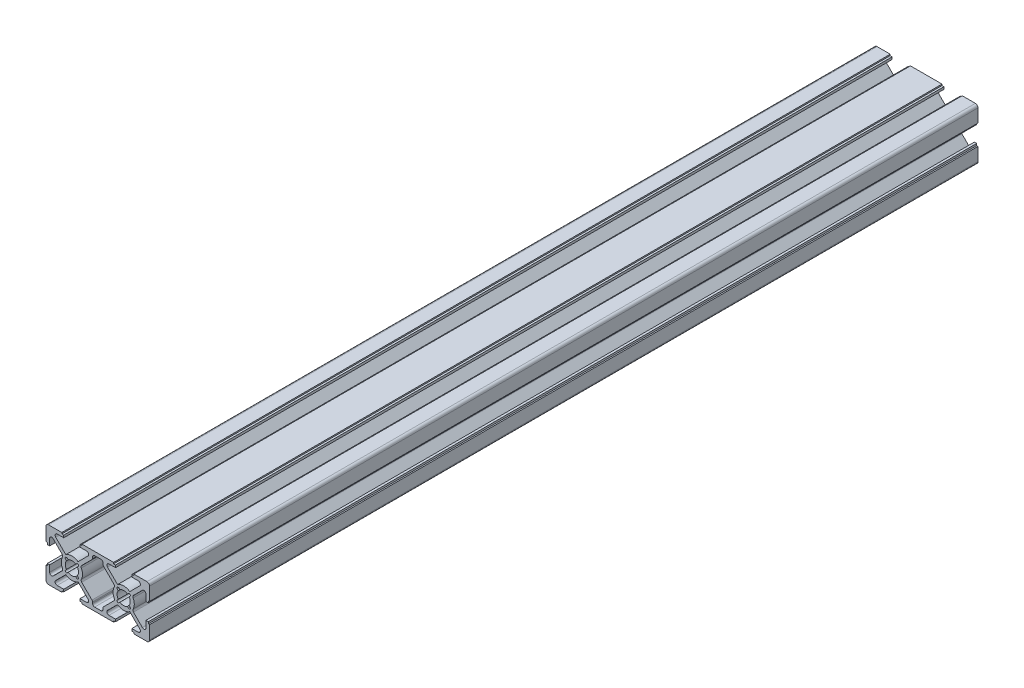
from build123d import *

# Parameters (mm, degrees)
Y_KSEKLIK_EKSTR_ZYON2_DEPTH = 160
RADYUS1_R                   = 0.8


with BuildPart() as part:
    # Çizim3 → Yükseklik-Ekstrüzyon2 (new body, symmetric)
    with BuildSketch(Plane.XY):
        with BuildLine():
            Line((1, 0), (6.1, 0))
            Line((6.1, 0), (6.1, 0.5))
            Line((6.1, 0.5), (6.85, 0.5))
            Line((6.85, 0.5), (6.85, 1.4))
            Line((6.85, 1.4), (4.321320344, 1.4))
            ThreePointArc((4.321320344, 1.4), (3.582216718, 1.893853254), (3.755634919, 2.765685425))
            Line((3.755634919, 2.765685425), (7.638403375, 6.648453882))
            ThreePointArc((7.638403375, 6.648453882), (10, 5.9), (12.361596625, 6.648453882))
            Line((12.361596625, 6.648453882), (16.244365081, 2.765685425))
            ThreePointArc((16.244365081, 2.765685425), (16.417783282, 1.893853254), (15.678679656, 1.4))
            Line((15.678679656, 1.4), (13.15, 1.4))
            Line((13.15, 1.4), (13.15, 0.5))
            Line((13.15, 0.5), (13.9, 0.5))
            Line((13.9, 0.5), (13.9, 0))
            Line((13.9, 0), (26.1, 0))
            Line((26.1, 0), (26.1, 0.5))
            Line((26.1, 0.5), (26.85, 0.5))
            Line((26.85, 0.5), (26.85, 1.4))
            Line((26.85, 1.4), (24.321320344, 1.4))
            ThreePointArc((24.321320344, 1.4), (23.582216718, 1.893853254), (23.755634919, 2.765685425))
            Line((23.755634919, 2.765685425), (27.638403375, 6.648453882))
            ThreePointArc((27.638403375, 6.648453882), (30, 5.9), (32.361596625, 6.648453882))
            Line((32.361596625, 6.648453882), (36.244365081, 2.765685425))
            ThreePointArc((36.244365081, 2.765685425), (36.417783282, 1.893853254), (35.678679656, 1.4))
            Line((35.678679656, 1.4), (33.15, 1.4))
            Line((33.15, 1.4), (33.15, 0.5))
            Line((33.15, 0.5), (33.9, 0.5))
            Line((33.9, 0.5), (33.9, 0))
            Line((33.9, 0), (39, 0))
            ThreePointArc((39, 0), (39.707106781, 0.292893219), (40, 1))
            Line((40, 1), (40, 6.1))
            Line((40, 6.1), (39.5, 6.1))
            Line((39.5, 6.1), (39.5, 6.85))
            Line((39.5, 6.85), (38.6, 6.85))
            Line((38.6, 6.85), (38.6, 4.321320344))
            ThreePointArc((38.6, 4.321320344), (38.106146746, 3.582216718), (37.234314575, 3.755634919))
            Line((37.234314575, 3.755634919), (33.351546118, 7.638403375))
            ThreePointArc((33.351546118, 7.638403375), (34.1, 10), (33.351546118, 12.361596625))
            Line((33.351546118, 12.361596625), (37.234314575, 16.244365081))
            ThreePointArc((37.234314575, 16.244365081), (38.106146746, 16.417783282), (38.6, 15.678679656))
            Line((38.6, 15.678679656), (38.6, 13.15))
            Line((38.6, 13.15), (39.5, 13.15))
            Line((39.5, 13.15), (39.5, 13.9))
            Line((39.5, 13.9), (40, 13.9))
            Line((40, 13.9), (40, 19))
            ThreePointArc((40, 19), (39.707106781, 19.707106781), (39, 20))
            Line((39, 20), (33.9, 20))
            Line((33.9, 20), (33.9, 19.5))
            Line((33.9, 19.5), (33.15, 19.5))
            Line((33.15, 19.5), (33.15, 18.6))
            Line((33.15, 18.6), (35.678679656, 18.6))
            ThreePointArc((35.678679656, 18.6), (36.417783282, 18.106146746), (36.244365081, 17.234314575))
            Line((36.244365081, 17.234314575), (32.361596625, 13.351546118))
            ThreePointArc((32.361596625, 13.351546118), (30, 14.1), (27.638403375, 13.351546118))
            Line((27.638403375, 13.351546118), (23.755634919, 17.234314575))
            ThreePointArc((23.755634919, 17.234314575), (23.582216718, 18.106146746), (24.321320344, 18.6))
            Line((24.321320344, 18.6), (26.85, 18.6))
            Line((26.85, 18.6), (26.85, 19.5))
            Line((26.85, 19.5), (26.1, 19.5))
            Line((26.1, 19.5), (26.1, 20))
            Line((26.1, 20), (13.9, 20))
            Line((13.9, 20), (13.9, 19.5))
            Line((13.9, 19.5), (13.15, 19.5))
            Line((13.15, 19.5), (13.15, 18.6))
            Line((13.15, 18.6), (15.678679656, 18.6))
            ThreePointArc((15.678679656, 18.6), (16.417783282, 18.106146746), (16.244365081, 17.234314575))
            Line((16.244365081, 17.234314575), (12.361596625, 13.351546118))
            ThreePointArc((12.361596625, 13.351546118), (10, 14.1), (7.638403375, 13.351546118))
            Line((7.638403375, 13.351546118), (3.755634919, 17.234314575))
            ThreePointArc((3.755634919, 17.234314575), (3.582216718, 18.106146746), (4.321320344, 18.6))
            Line((4.321320344, 18.6), (6.85, 18.6))
            Line((6.85, 18.6), (6.85, 19.5))
            Line((6.85, 19.5), (6.1, 19.5))
            Line((6.1, 19.5), (6.1, 20))
            Line((6.1, 20), (1, 20))
            ThreePointArc((1, 20), (0.292893219, 19.707106781), (0, 19))
            Line((0, 19), (0, 13.9))
            Line((0, 13.9), (0.5, 13.9))
            Line((0.5, 13.9), (0.5, 13.15))
            Line((0.5, 13.15), (1.4, 13.15))
            Line((1.4, 13.15), (1.4, 15.678679656))
            ThreePointArc((1.4, 15.678679656), (1.893853254, 16.417783282), (2.765685425, 16.244365081))
            Line((2.765685425, 16.244365081), (6.648453882, 12.361596625))
            ThreePointArc((6.648453882, 12.361596625), (5.9, 10), (6.648453882, 7.638403375))
            Line((6.648453882, 7.638403375), (2.765685425, 3.755634919))
            ThreePointArc((2.765685425, 3.755634919), (1.893853254, 3.582216718), (1.4, 4.321320344))
            Line((1.4, 4.321320344), (1.4, 6.85))
            Line((1.4, 6.85), (0.5, 6.85))
            Line((0.5, 6.85), (0.5, 6.1))
            Line((0.5, 6.1), (0, 6.1))
            Line((0, 6.1), (0, 1))
            ThreePointArc((0, 1), (0.292893219, 0.292893219), (1, 0))
        make_face()
        with BuildLine():
            Line((21.210320913, 18.6), (18.789679087, 18.6))
            ThreePointArc((18.789679087, 18.6), (18.223993662, 18.365685425), (17.989679087, 17.8))
            Line((17.989679087, 17.8), (17.989679087, 17.331100443))
            ThreePointArc((17.989679087, 17.331100443), (17.928782713, 17.024953697), (17.755364512, 16.765415018))
            Line((17.755364512, 16.765415018), (13.351546118, 12.361596625))
            ThreePointArc((13.351546118, 12.361596625), (14.1, 10), (13.351546118, 7.638403375))
            Line((13.351546118, 7.638403375), (17.755364512, 3.234584982))
            ThreePointArc((17.755364512, 3.234584982), (17.928782713, 2.975046303), (17.989679087, 2.668899557))
            Line((17.989679087, 2.668899557), (17.989679087, 2.2))
            ThreePointArc((17.989679087, 2.2), (18.223993662, 1.634314575), (18.789679087, 1.4))
            Line((18.789679087, 1.4), (21.210320913, 1.4))
            ThreePointArc((21.210320913, 1.4), (21.776006338, 1.634314575), (22.010320913, 2.2))
            Line((22.010320913, 2.2), (22.010320913, 2.668899557))
            ThreePointArc((22.010320913, 2.668899557), (22.071217287, 2.975046303), (22.244635488, 3.234584982))
            Line((22.244635488, 3.234584982), (26.648453882, 7.638403375))
            ThreePointArc((26.648453882, 7.638403375), (25.9, 10), (26.648453882, 12.361596625))
            Line((26.648453882, 12.361596625), (22.244635488, 16.765415018))
            ThreePointArc((22.244635488, 16.765415018), (22.071217287, 17.024953697), (22.010320913, 17.331100443))
            Line((22.010320913, 17.331100443), (22.010320913, 17.8))
            ThreePointArc((22.010320913, 17.8), (21.776006338, 18.365685425), (21.210320913, 18.6))
        make_face(mode=Mode.SUBTRACT)
        with BuildLine():
            Line((8.201142588, 12.443783276), (8.552743846, 12.092182018))
            ThreePointArc((8.552743846, 12.092182018), (10, 12.543968548), (11.447256154, 12.092182018))
            Line((11.447256154, 12.092182018), (11.798857412, 12.443783276))
            ThreePointArc((11.798857412, 12.443783276), (12.443783276, 12.443783276), (12.443783276, 11.798857412))
            Line((12.443783276, 11.798857412), (12.092182018, 11.447256154))
            ThreePointArc((12.092182018, 11.447256154), (12.543968548, 10), (12.092182018, 8.552743846))
            Line((12.092182018, 8.552743846), (12.443783276, 8.201142588))
            ThreePointArc((12.443783276, 8.201142588), (12.443783276, 7.556216724), (11.798857412, 7.556216724))
            Line((11.798857412, 7.556216724), (11.447256154, 7.907817982))
            ThreePointArc((11.447256154, 7.907817982), (10, 7.456031452), (8.552743846, 7.907817982))
            Line((8.552743846, 7.907817982), (8.201142588, 7.556216724))
            ThreePointArc((8.201142588, 7.556216724), (7.556216724, 7.556216724), (7.556216724, 8.201142588))
            Line((7.556216724, 8.201142588), (7.907817982, 8.552743846))
            ThreePointArc((7.907817982, 8.552743846), (7.456031452, 10), (7.907817982, 11.447256154))
            Line((7.907817982, 11.447256154), (7.556216724, 11.798857412))
            ThreePointArc((7.556216724, 11.798857412), (7.556216724, 12.443783276), (8.201142588, 12.443783276))
        make_face(mode=Mode.SUBTRACT)
        with BuildLine():
            Line((27.907817982, 11.447256154), (27.556216724, 11.798857412))
            ThreePointArc((27.556216724, 11.798857412), (27.556216724, 12.443783276), (28.201142588, 12.443783276))
            Line((28.201142588, 12.443783276), (28.552743846, 12.092182018))
            ThreePointArc((28.552743846, 12.092182018), (30, 12.543968548), (31.447256154, 12.092182018))
            Line((31.447256154, 12.092182018), (31.798857412, 12.443783276))
            ThreePointArc((31.798857412, 12.443783276), (32.443783276, 12.443783276), (32.443783276, 11.798857412))
            Line((32.443783276, 11.798857412), (32.092182018, 11.447256154))
            ThreePointArc((32.092182018, 11.447256154), (32.543968548, 10), (32.092182018, 8.552743846))
            Line((32.092182018, 8.552743846), (32.443783276, 8.201142588))
            ThreePointArc((32.443783276, 8.201142588), (32.443783276, 7.556216724), (31.798857412, 7.556216724))
            Line((31.798857412, 7.556216724), (31.447256154, 7.907817982))
            ThreePointArc((31.447256154, 7.907817982), (30, 7.456031452), (28.552743846, 7.907817982))
            Line((28.552743846, 7.907817982), (28.201142588, 7.556216724))
            ThreePointArc((28.201142588, 7.556216724), (27.556216724, 7.556216724), (27.556216724, 8.201142588))
            Line((27.556216724, 8.201142588), (27.907817982, 8.552743846))
            ThreePointArc((27.907817982, 8.552743846), (27.456031452, 10), (27.907817982, 11.447256154))
        make_face(mode=Mode.SUBTRACT)
    extrude(amount=Y_KSEKLIK_EKSTR_ZYON2_DEPTH, both=True)

    # Radyus1
    radyus1_edges = [part.edges().sort_by_distance(p)[0] for p in [
        (6.648453882, 7.638403375, 0),
        (6.648453882, 12.361596625, 0),
        (33.351546118, 12.361596625, 0),
        (33.351546118, 7.638403375, 0),
        (13.351546118, 12.361596625, 0),
        (13.351546118, 7.638403375, 0),
        (26.648453882, 7.638403375, 0),
        (26.648453882, 12.361596625, 0),
    ]]
    fillet(radyus1_edges, radius=RADYUS1_R)


solid = part.part
